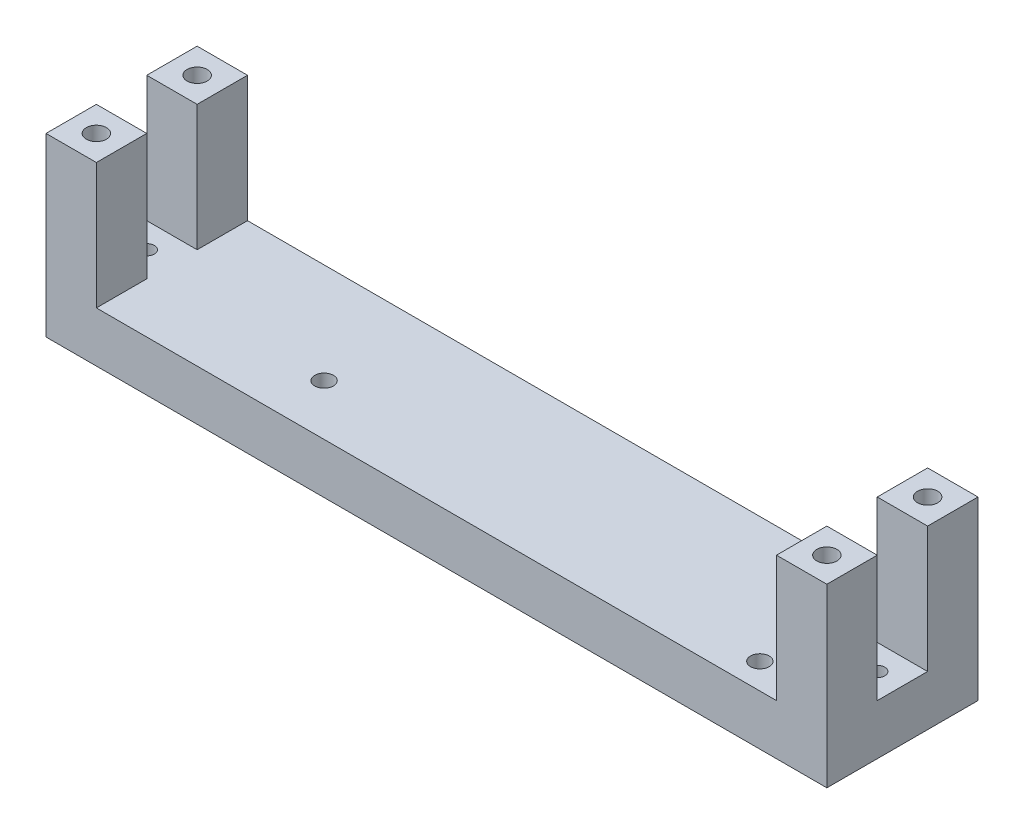
from build123d import *

# Parameters (mm, degrees)
SKETCH3_W           = 155
SKETCH3_H           = 30
BOSS_EXTRUDE3_DEPTH = 10
SKETCH4_W           = 10
SKETCH4_H           = 10
BOSS_EXTRUDE4_DEPTH = 25
SKETCH6_R           = 2
CUT_EXTRUDE1_DEPTH  = 10
SKETCH7_R           = 1.5
SKETCH7_R_2         = 1.85
CUT_EXTRUDE2_DEPTH  = 10


with BuildPart() as part:
    # Sketch3 → Boss-Extrude3 (new body)
    with BuildSketch(Plane(origin=(0, 0, 0), x_dir=(1, 0, 0), z_dir=(0, 1, 0))):
        with Locations((23.197278912, 148.962585034)):
            Rectangle(SKETCH3_W, SKETCH3_H)
    extrude(amount=BOSS_EXTRUDE3_DEPTH)

    # Sketch4 → Boss-Extrude4 (add)
    with BuildSketch(Plane(origin=(0, 10, 0), x_dir=(1, 0, 0), z_dir=(0, 1, 0))):
        with Locations((-49.302721088, 158.962585034)):
            Rectangle(SKETCH4_W, SKETCH4_H)
        with Locations((-49.302721088, 138.962585034)):
            Rectangle(SKETCH4_W, SKETCH4_H)
        with Locations((95.697278912, 158.962585034)):
            Rectangle(SKETCH4_W, SKETCH4_H)
        with Locations((95.697278912, 138.962585034)):
            Rectangle(SKETCH4_W, SKETCH4_H)
    extrude(amount=BOSS_EXTRUDE4_DEPTH)

    # Sketch6 → Cut-Extrude1 (cut)
    with BuildSketch(Plane(origin=(0, 35, 0), x_dir=(1, 0, 0), z_dir=(0, 1, 0))):
        with Locations((95.697278912, 138.962585034)):
            Circle(SKETCH6_R)
        with Locations((95.697278912, 158.962585034)):
            Circle(SKETCH6_R)
        with Locations((-49.302721088, 138.962585034)):
            Circle(SKETCH6_R)
        with Locations((-49.302721088, 158.962585034)):
            Circle(SKETCH6_R)
    extrude(amount=-CUT_EXTRUDE1_DEPTH, mode=Mode.SUBTRACT)

    # Sketch7 → Cut-Extrude2 (cut)
    with BuildSketch(Plane(origin=(0, 10, 0), x_dir=(1, 0, 0), z_dir=(0, 1, 0))):
        with Locations((95.697278912, 148.962585034)):
            Circle(SKETCH7_R)
        with Locations((82.297278912, 139.062585034)):
            Circle(SKETCH7_R_2)
        with Locations((82.297278912, 159.062585034)):
            Circle(SKETCH7_R_2)
        with Locations((-49.302721088, 148.962585034)):
            Circle(SKETCH7_R)
        with Locations((-9.202721088, 144.062585034)):
            Circle(SKETCH7_R_2)
    extrude(amount=-CUT_EXTRUDE2_DEPTH, mode=Mode.SUBTRACT)


solid = part.part
